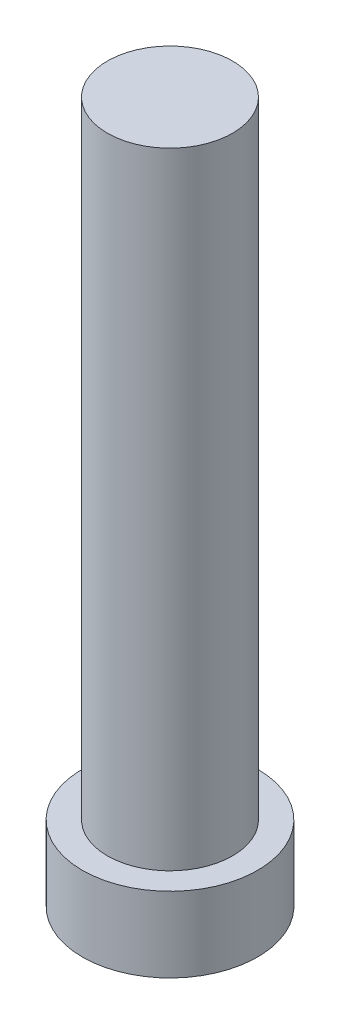
from build123d import *

# Parameters (mm, degrees)
SKETCH1_R           = 3.5
BOSS_EXTRUDE1_DEPTH = 3
SKETCH2_R           = 2.5
BOSS_EXTRUDE2_DEPTH = 25


with BuildPart() as part:
    # Sketch1 → Boss-Extrude1 (new body)
    with BuildSketch(Plane(origin=(0, 0, 0), x_dir=(1, 0, 0), z_dir=(0, 1, 0))):
        Circle(SKETCH1_R)
    extrude(amount=BOSS_EXTRUDE1_DEPTH)

    # Sketch2 → Boss-Extrude2 (add)
    with BuildSketch(Plane(origin=(0, 3, 0), x_dir=(1, 0, 0), z_dir=(0, 1, 0))):
        Circle(SKETCH2_R)
    extrude(amount=BOSS_EXTRUDE2_DEPTH)


solid = part.part
